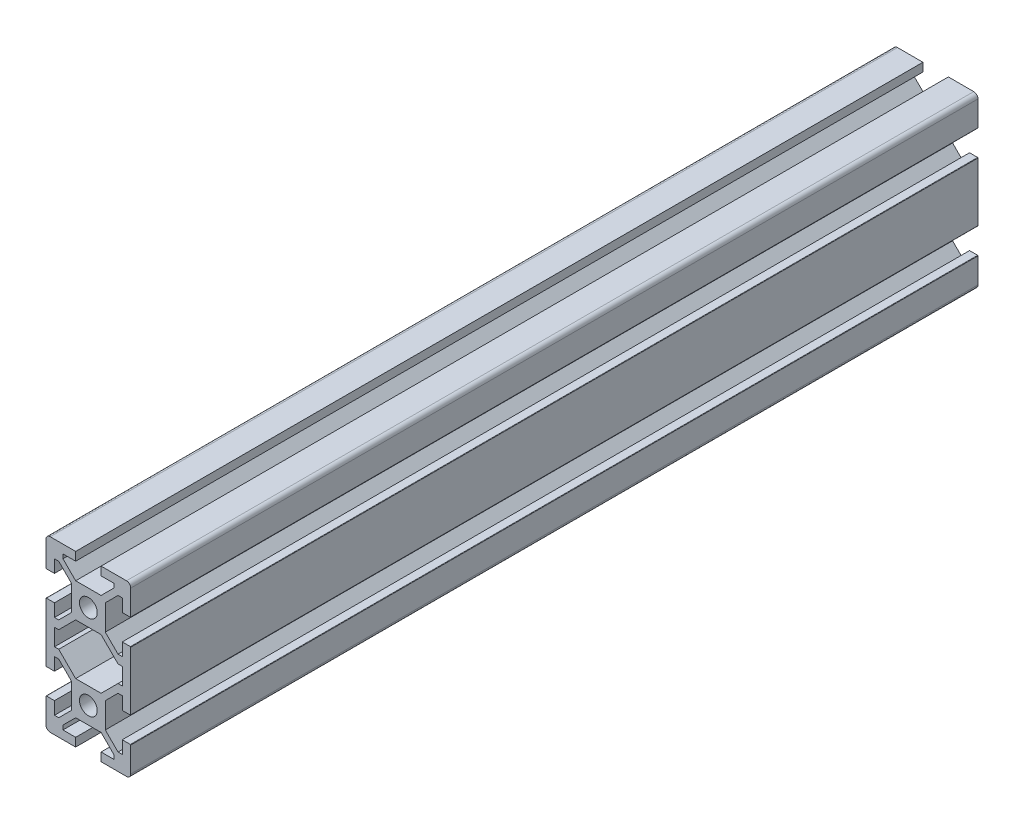
from build123d import *

# Parameters (mm, degrees)
SKETCH1_R           = 2.1
BOSS_EXTRUDE1_DEPTH = 200
FILLET1_R           = 0.1


with BuildPart() as part:
    # Sketch1 → Boss-Extrude1 (new body)
    with BuildSketch(Plane.XY):
        with BuildLine():
            Line((10, -19), (10, -13))
            Line((10, -13), (8, -13))
            Line((8, -13), (8, -16))
            Line((8, -16), (7, -16))
            Line((7, -16), (4, -13))
            Line((4, -13), (4, -7))
            Line((4, -7), (7, -4))
            Line((7, -4), (8, -4))
            Line((8, -4), (8, -7))
            Line((8, -7), (10, -7))
            Line((10, -7), (10, 7))
            Line((10, 7), (8, 7))
            Line((8, 7), (8, 4))
            Line((8, 4), (7, 4))
            Line((7, 4), (4, 7))
            Line((4, 7), (4, 13))
            Line((4, 13), (7, 16))
            Line((7, 16), (8, 16))
            Line((8, 16), (8, 13))
            Line((8, 13), (10, 13))
            Line((10, 13), (10, 19))
            ThreePointArc((10, 19), (9.707106781, 19.707106781), (9, 20))
            Line((9, 20), (3, 20))
            Line((3, 20), (3, 18))
            Line((3, 18), (6, 18))
            Line((6, 18), (6, 17))
            Line((6, 17), (3, 14))
            Line((3, 14), (-3, 14))
            Line((-3, 14), (-6, 17))
            Line((-6, 17), (-6, 18))
            Line((-6, 18), (-3, 18))
            Line((-3, 18), (-3, 20))
            Line((-3, 20), (-9, 20))
            ThreePointArc((-9, 20), (-9.707106781, 19.707106781), (-10, 19))
            Line((-10, 19), (-10, 13))
            Line((-10, 13), (-8, 13))
            Line((-8, 13), (-8, 16))
            Line((-8, 16), (-7, 16))
            Line((-7, 16), (-4, 13))
            Line((-4, 13), (-4, 7))
            Line((-4, 7), (-7, 4))
            Line((-7, 4), (-8, 4))
            Line((-8, 4), (-8, 7))
            Line((-8, 7), (-10, 7))
            Line((-10, 7), (-10, -7))
            Line((-10, -7), (-8, -7))
            Line((-8, -7), (-8, -4))
            Line((-8, -4), (-7, -4))
            Line((-7, -4), (-4, -7))
            Line((-4, -7), (-4, -13))
            Line((-4, -13), (-7, -16))
            Line((-7, -16), (-8, -16))
            Line((-8, -16), (-8, -13))
            Line((-8, -13), (-10, -13))
            Line((-10, -13), (-10, -19))
            ThreePointArc((-10, -19), (-9.707106781, -19.707106781), (-9, -20))
            Line((-9, -20), (-3, -20))
            Line((-3, -20), (-3, -18))
            Line((-3, -18), (-6, -18))
            Line((-6, -18), (-6, -17))
            Line((-6, -17), (-3, -14))
            Line((-3, -14), (3, -14))
            Line((3, -14), (6, -17))
            Line((6, -17), (6, -18))
            Line((6, -18), (3, -18))
            Line((3, -18), (3, -20))
            Line((3, -20), (9, -20))
            ThreePointArc((9, -20), (9.707106781, -19.707106781), (10, -19))
        make_face()
        with Locations((0, -10)):
            Circle(SKETCH1_R, mode=Mode.SUBTRACT)
        with Locations((0, 10)):
            Circle(SKETCH1_R, mode=Mode.SUBTRACT)
        Polygon((-7, -2), (-8, -2), (-8, 2), (-7, 2), (-3, 6), (3, 6), (7, 2), (8, 2), (8, -2), (7, -2), (3, -6), (-3, -6), align=None, mode=Mode.SUBTRACT)
    extrude(amount=-BOSS_EXTRUDE1_DEPTH)

    # Fillet1
    fillet1_edges = [part.edges().sort_by_distance(p)[0] for p in [
        (-10, -13, -100),
        (-10, -7, -100),
        (-10, 7, -100),
        (-10, 13, -100),
        (10, 13, -100),
        (10, 7, -100),
        (10, -7, -100),
        (10, -13, -100),
    ]]
    fillet(fillet1_edges, radius=FILLET1_R)


solid = part.part
